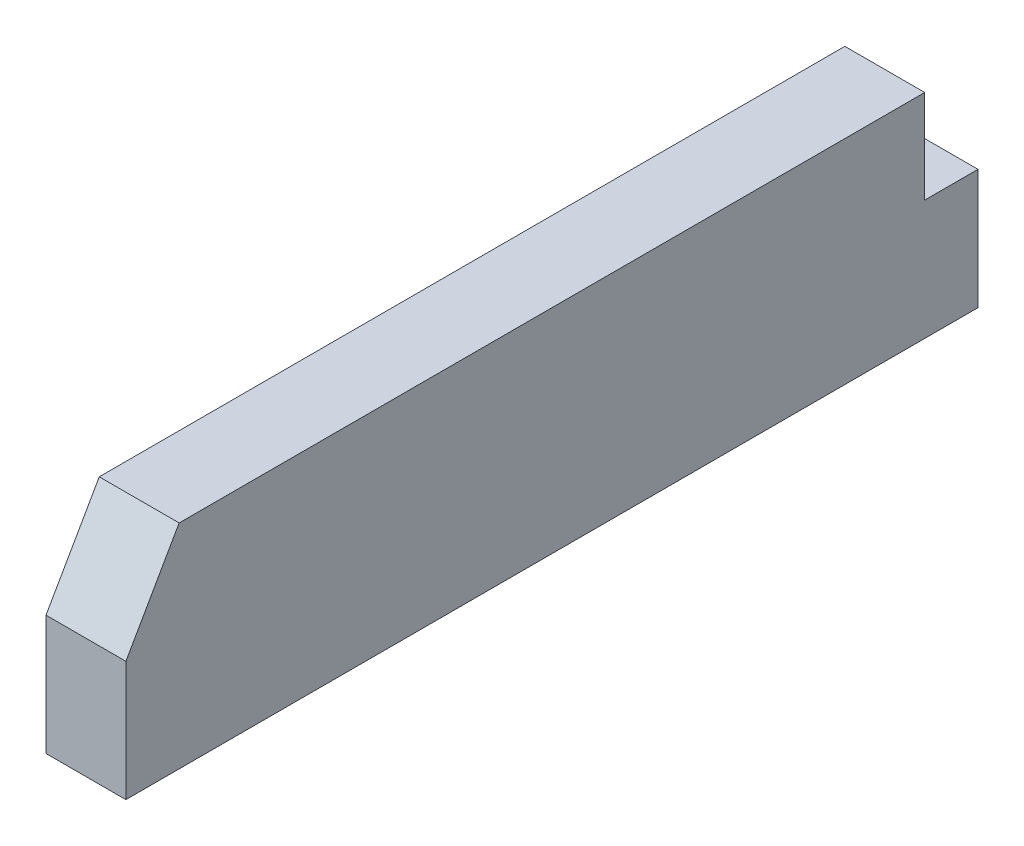
from build123d import *

# Parameters (mm, degrees)
BOSS_EXTRUDE1_DEPTH = 9.525


with BuildPart() as part:
    # Sketch2 → Boss-Extrude1 (new body)
    with BuildSketch(Plane(origin=(0, 0, 0), x_dir=(0, 0, -1), z_dir=(1, 0, 0))):
        Polygon((0, 0), (-88.9, 0), (-95.25, -11.1125), (-95.25, -25.4), (6.35, -25.4), (6.35, -11.1125), (0, -11.1125), align=None)
    extrude(amount=BOSS_EXTRUDE1_DEPTH)


solid = part.part
